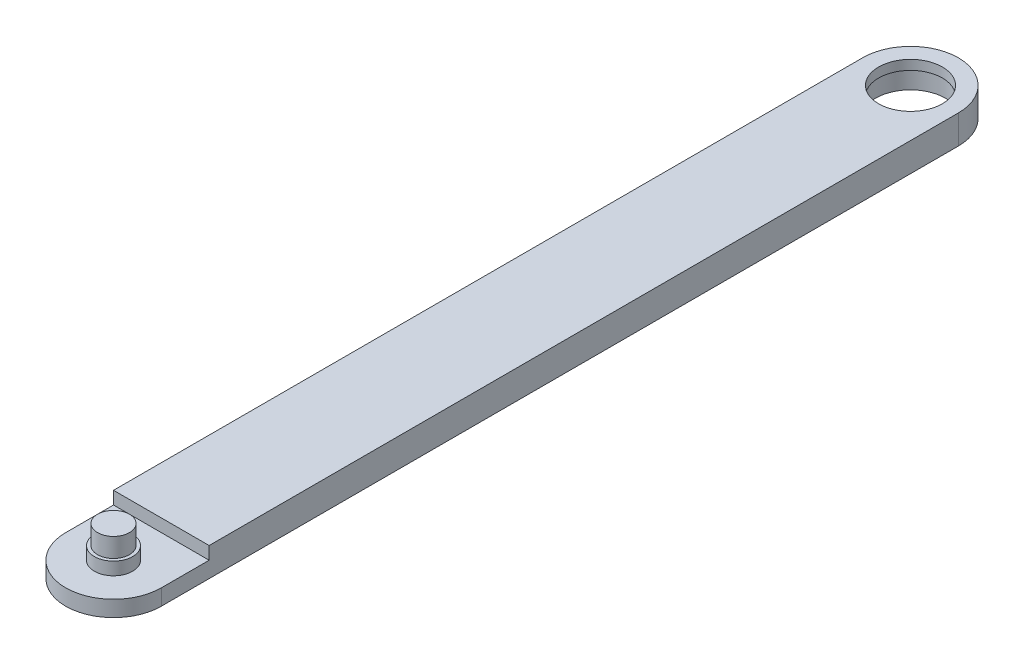
from build123d import *

# Parameters (mm, degrees)
SKETCH_1_R          = 6
EXTRUDE_1_DEPTH     = 1
EXTRUDE_2_DEPTH     = 9
SKETCH_8_W          = 30
SKETCH_8_H          = 30
CUT_EXTRUDE_2_DEPTH = 4
SKETCH_9_R          = 6
EXTRUDE_6_DEPTH     = 4
SKETCH_10_R         = 5
EXTRUDE_7_DEPTH     = 6
SKETCH_11_R         = 11
CUT_EXTRUDE_3_DEPTH = 7
SKETCH_12_R         = 10
CUT_EXTRUDE_4_DEPTH = 10


with BuildPart() as part:
    # 스케치1 → 보스-돌출1 (new body)
    with BuildSketch(Plane(origin=(0, 0, 0), x_dir=(1, 0, 0), z_dir=(0, 1, 0))):
        Circle(SKETCH_1_R)
    extrude(amount=EXTRUDE_1_DEPTH)

    # 스케치2 → 보스-돌출2 (add)
    with BuildSketch(Plane(origin=(0, 1, 0), x_dir=(1, 0, 0), z_dir=(0, 1, 0))):
        with BuildLine():
            Line((-15, 0), (-15, -250))
            ThreePointArc((-15, -250), (0, -265), (15, -250))
            Line((15, -250), (15, 0))
            ThreePointArc((15, 0), (0, 15), (-15, 0))
        make_face()
    extrude(amount=EXTRUDE_2_DEPTH)

    # 스케치8 → 컷-돌출2 (cut)
    with BuildSketch(Plane(origin=(0, 10, 0), x_dir=(1, 0, 0), z_dir=(0, 1, 0))):
        with Locations((0, -250)):
            Rectangle(SKETCH_8_W, SKETCH_8_H)
    extrude(amount=-CUT_EXTRUDE_2_DEPTH, mode=Mode.SUBTRACT)

    # 스케치9 → 보스-돌출6 (add)
    with BuildSketch(Plane(origin=(0, 6, 0), x_dir=(1, 0, 0), z_dir=(0, 1, 0))):
        with Locations((0, -250)):
            Circle(SKETCH_9_R)
    extrude(amount=EXTRUDE_6_DEPTH)

    # 스케치10 → 보스-돌출7 (add)
    with BuildSketch(Plane(origin=(0, 10, 0), x_dir=(1, 0, 0), z_dir=(0, 1, 0))):
        with Locations((0, -250)):
            Circle(SKETCH_10_R)
    extrude(amount=EXTRUDE_7_DEPTH)

    # 스케치11 → 컷-돌출3 (cut)
    with BuildSketch(Plane.XZ):
        Circle(SKETCH_11_R)
    extrude(amount=-CUT_EXTRUDE_3_DEPTH, mode=Mode.SUBTRACT)

    # 스케치12 → 컷-돌출4 (cut, through all)
    with BuildSketch(Plane.XZ.offset(-7)):
        Circle(SKETCH_12_R)
    extrude(amount=-CUT_EXTRUDE_4_DEPTH, mode=Mode.SUBTRACT)


solid = part.part
